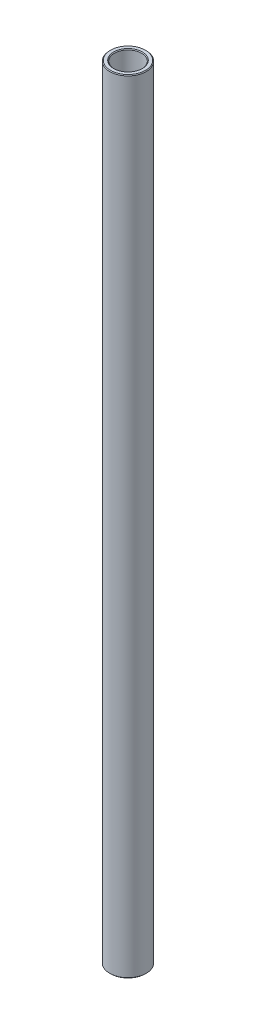
from build123d import *

# Parameters (mm, degrees)
SKETCH1_W     = 1.5875
SKETCH1_H     = 273.05
CHAMFER1_SIZE = 0.254


with BuildPart() as part:
    # Sketch1 → Revolve1 (revolve)
    with BuildSketch(Plane.XY):
        with Locations((5.55625, 0)):
            Rectangle(SKETCH1_W, SKETCH1_H)
    revolve(axis=Axis((0, 11.60859375, 0), (0, -1, 0)))

    # Chamfer1
    chamfer1_edges = [part.edges().sort_by_distance(p)[0] for p in [
        (-4.7625, -136.525, 0),
        (-6.35, -136.525, 0),
        (-6.35, 136.525, 0),
        (-4.7625, 136.525, 0),
    ]]
    chamfer(chamfer1_edges, length=CHAMFER1_SIZE)


solid = part.part
